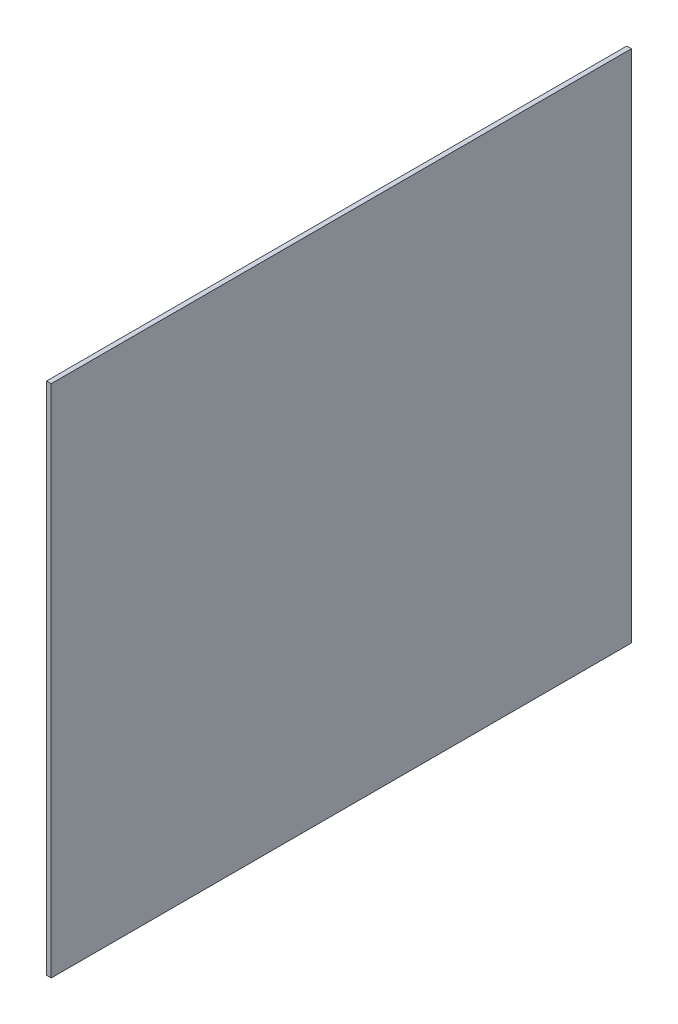
from build123d import *

# Parameters (mm, degrees)
CROQUIS1_W              = 12.4
CROQUIS1_H              = 11
SALIENTE_EXTRUIR1_DEPTH = 0.1


with BuildPart() as part:
    # Croquis1 → Saliente-Extruir1 (new body)
    with BuildSketch(Plane(origin=(0, 0, 0), x_dir=(0, 0, -1), z_dir=(1, 0, 0))):
        with Locations((6.2, 5.5)):
            Rectangle(CROQUIS1_W, CROQUIS1_H)
    extrude(amount=SALIENTE_EXTRUIR1_DEPTH)


solid = part.part
